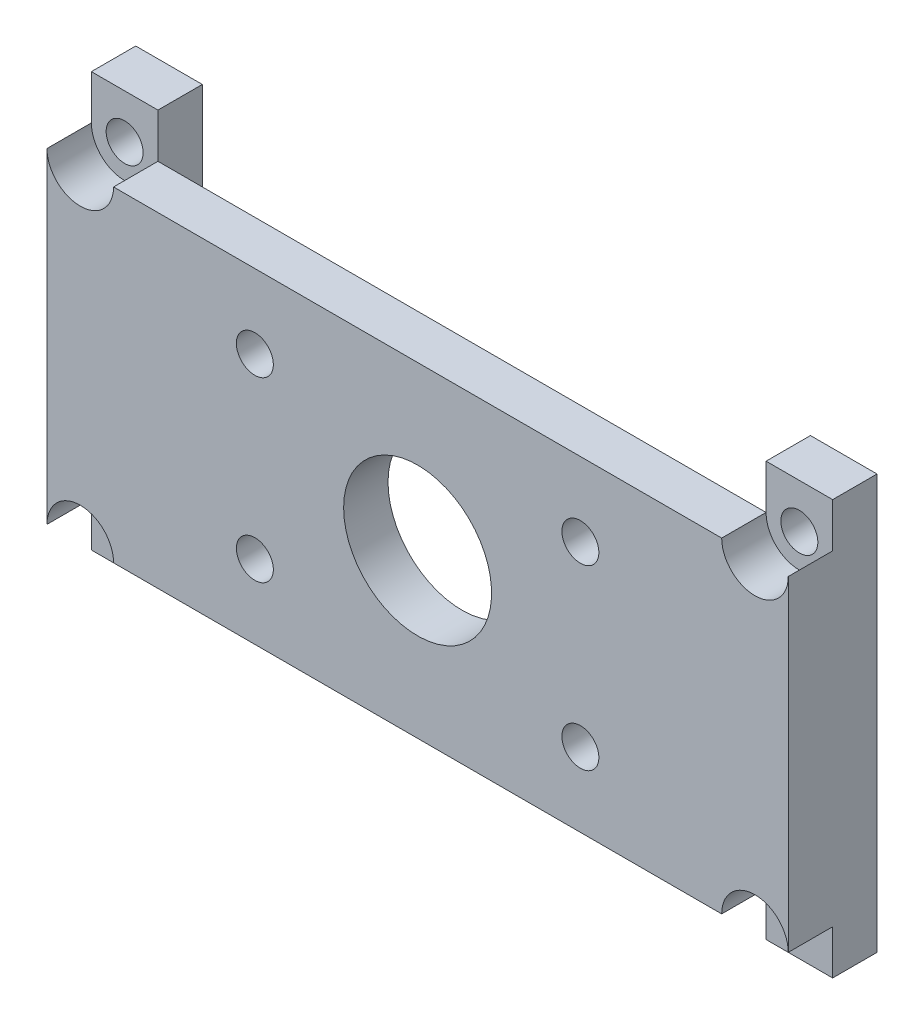
from build123d import *

# Parameters (mm, degrees)
SKETCH_1_W          = 4.5
SKETCH_1_H          = 28
EXTRUDE_1_DEPTH     = 3
SKETCH_4_W          = 50.1
SKETCH_4_H          = 22
EXTRUDE_2_DEPTH     = 3
SKETCH_5_W          = 4.5
SKETCH_5_H          = 28
EXTRUDE_3_DEPTH     = 3
SKETCH_6_R          = 1.25
CUT_EXTRUDE_2_DEPTH = 7
SKETCH_2_R          = 1.25
CUT_EXTRUDE_1_DEPTH = 4
SKETCH_7_R          = 5
SKETCH_7_R_2        = 1.25
CUT_EXTRUDE_3_DEPTH = 4
SKETCH_10_R         = 2.25
CUT_EXTRUDE_4_DEPTH = 3


with BuildPart() as part:
    # 스케치1 → 보스-돌출1 (new body)
    with BuildSketch(Plane.XY):
        with Locations((2.25, 14)):
            Rectangle(SKETCH_1_W, SKETCH_1_H)
    extrude(amount=EXTRUDE_1_DEPTH)

    # 스케치4 → 보스-돌출2 (add)
    with BuildSketch(Plane.XY.offset(3)):
        with Locations((25.05, 14)):
            Rectangle(SKETCH_4_W, SKETCH_4_H)
    extrude(amount=EXTRUDE_2_DEPTH)

    # 스케치5 → 보스-돌출3 (add)
    with BuildSketch(Plane(origin=(0, 0, 3), x_dir=(-1, 0, 0), z_dir=(0, 0, -1))):
        with Locations((-47.85, 14)):
            Rectangle(SKETCH_5_W, SKETCH_5_H)
    extrude(amount=EXTRUDE_3_DEPTH)

    # 스케치6 → 컷-돌출2 (cut, through all)
    with BuildSketch(Plane(origin=(0, 0, 0), x_dir=(-1, 0, 0), z_dir=(0, 0, -1))):
        with Locations((-47.85, 25)):
            Circle(SKETCH_6_R)
        with Locations((-47.85, 3)):
            Circle(SKETCH_6_R)
    extrude(amount=-CUT_EXTRUDE_2_DEPTH, mode=Mode.SUBTRACT)

    # 스케치2 → 컷-돌출1 (cut, through all)
    with BuildSketch(Plane.XY.offset(3)):
        with Locations((2.25, 25)):
            Circle(SKETCH_2_R)
        with Locations((2.25, 3)):
            Circle(SKETCH_2_R)
    extrude(amount=-CUT_EXTRUDE_1_DEPTH, mode=Mode.SUBTRACT)

    # 스케치7 → 컷-돌출3 (cut, through all)
    with BuildSketch(Plane(origin=(0, 0, 3), x_dir=(-1, 0, 0), z_dir=(0, 0, -1))):
        with Locations((-25.05, 14)):
            Circle(SKETCH_7_R)
        with Locations((-36.05, 20)):
            Circle(SKETCH_7_R_2)
        with Locations((-14.05, 20)):
            Circle(SKETCH_7_R_2)
        with Locations((-36.05, 8)):
            Circle(SKETCH_7_R_2)
        with Locations((-14.05, 8)):
            Circle(SKETCH_7_R_2)
    extrude(amount=-CUT_EXTRUDE_3_DEPTH, mode=Mode.SUBTRACT)

    # 스케치10 → 컷-돌출4 (cut)
    with BuildSketch(Plane.XY.offset(6)):
        with Locations((2.25, 25)):
            Circle(SKETCH_10_R)
        with Locations((2.25, 3)):
            Circle(SKETCH_10_R)
        with Locations((47.85, 25)):
            Circle(SKETCH_10_R)
        with Locations((47.85, 3)):
            Circle(SKETCH_10_R)
    extrude(amount=-CUT_EXTRUDE_4_DEPTH, mode=Mode.SUBTRACT)


solid = part.part
